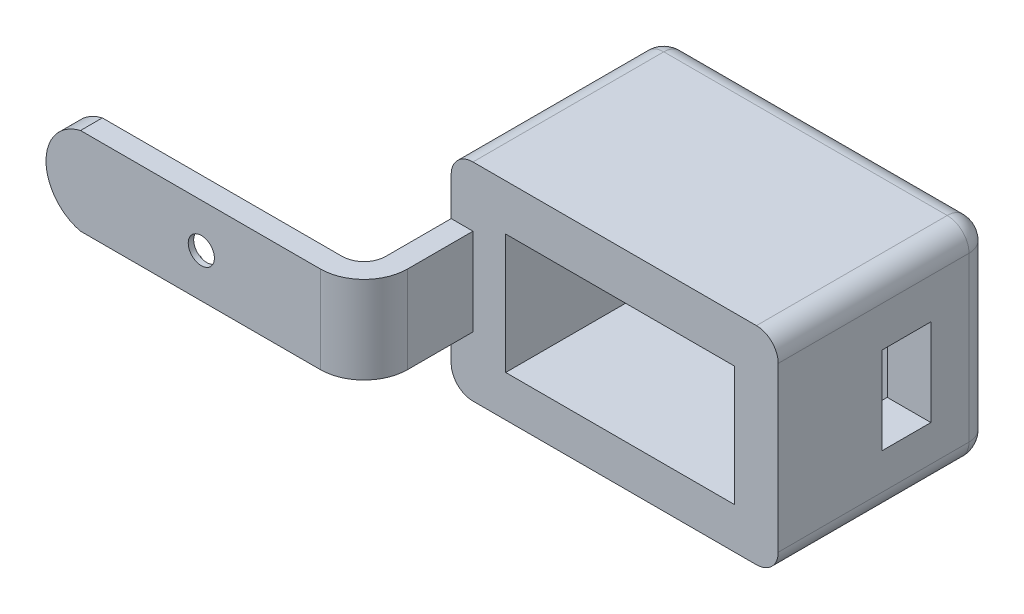
from build123d import *

# Parameters (mm, degrees)
BOSS_EXTRUDE1_DEPTH  = 4
CUT_EXTRUDE1_DEPTH   = 3
SKETCH5_W            = 51
SKETCH5_H            = 16
BOSS_EXTRUDE2_DEPTH  = 4
BOSS_EXTRUDE15_DEPTH = 31
SKETCH20_R           = 2.4
CUT_EXTRUDE26_DEPTH  = 1
FILLET8_R            = 4
FILLET12_R           = 8
CUT_EXTRUDE_8_DEPTH  = 29
SKETCH_8_W           = 9
SKETCH_8_H           = 16
CUT_EXTRUDE_10_DEPTH = 8
SKETCH_10_W          = 60
SKETCH_10_H          = 38
EXTRUDE_2_DEPTH      = 8
FILLET_3_R           = 4
FILLET_4_R           = 4
FILLET_5_R           = 4
FILLET_6_R           = 4


with BuildPart() as part:
    # Sketch2 → Boss-Extrude1 (new body)
    with BuildSketch(Plane.XY):
        with BuildLine():
            Line((23.733047461, 11.63962887), (23.733047461, -4.36037113))
            Line((23.733047461, -4.36037113), (-24.266952539, -4.36037113))
            ThreePointArc((-24.266952539, -4.36037113), (-30.597931628, 3.63962887), (-24.266952539, 11.63962887))
            Line((-24.266952539, 11.63962887), (23.733047461, 11.63962887))
        make_face()
    extrude(amount=BOSS_EXTRUDE1_DEPTH)

    # Sketch1 → Cut-Extrude1 (cut)
    with BuildSketch(Plane.XY):
        with BuildLine():
            Line((-6.25004119, 8.63962887), (-20.04279291, 6.23962887))
            ThreePointArc((-20.04279291, 6.23962887), (-22.105421524, 3.63962887), (-20.04279291, 1.03962887))
            Line((-20.04279291, 1.03962887), (-6.25004119, -1.36037113))
            ThreePointArc((-6.25004119, -1.36037113), (-2.105421524, -2.86037113), (2.039198142, -1.36037113))
            Line((2.039198142, -1.36037113), (15.831949862, 1.03962887))
            ThreePointArc((15.831949862, 1.03962887), (17.894578476, 3.63962887), (15.831949862, 6.23962887))
            Line((15.831949862, 6.23962887), (2.039198142, 8.63962887))
            ThreePointArc((2.039198142, 8.63962887), (-2.105421524, 10.13962887), (-6.25004119, 8.63962887))
        make_face()
    extrude(amount=CUT_EXTRUDE1_DEPTH, mode=Mode.SUBTRACT)

    # Sketch5 → Boss-Extrude2 (add)
    with BuildSketch(Plane(origin=(23.733047461, 0, 0), x_dir=(0, 0, -1), z_dir=(1, 0, 0))):
        with Locations((21.5, 3.63962887)):
            Rectangle(SKETCH5_W, SKETCH5_H)
    extrude(amount=BOSS_EXTRUDE2_DEPTH)

    # Sketch6 → Boss-Extrude15 (add)
    with BuildSketch(Plane(origin=(0, 0, -47), x_dir=(-1, 0, 0), z_dir=(0, 0, -1))):
        Polygon((-30.946192459, -15.36037113), (-83.733047461, -15.36037113), (-83.733047461, 22.63962887), (-23.733047461, 22.63962887), (-23.733047461, -15.36037113), align=None)
    extrude(amount=-BOSS_EXTRUDE15_DEPTH)

    # Sketch20 → Cut-Extrude26 (cut)
    with BuildSketch(Plane(origin=(0, 0, 3), x_dir=(-1, 0, 0), z_dir=(0, 0, -1))):
        with Locations((2.105421524, 3.63962887)):
            Circle(SKETCH20_R)
    extrude(amount=-CUT_EXTRUDE26_DEPTH, mode=Mode.SUBTRACT)

    # Fillet8
    fillet8_edges = [part.edges().sort_by_distance(p)[0] for p in [
        (23.733047461, 3.63962887, 0),
    ]]
    fillet(fillet8_edges, radius=FILLET8_R)

    # Fillet12
    fillet12_edges = [part.edges().sort_by_distance(p)[0] for p in [
        (27.733047461, 3.63962887, 4),
    ]]
    fillet(fillet12_edges, radius=FILLET12_R)

    # 草圖5 → 除料-伸長8 (cut)
    with BuildSketch(Plane.XY.offset(-16)):
        Polygon((75.733047461, -7.806095257), (75.733047461, 14.193904743), (33.733047461, 14.193904743), (33.733047461, 3.193904743), (33.733047461, -7.806095257), align=None)
    extrude(amount=-CUT_EXTRUDE_8_DEPTH, mode=Mode.SUBTRACT)

    # 草圖8 → 除料-伸長10 (cut)
    with BuildSketch(Plane(origin=(83.733047461, 0, 0), x_dir=(0, 0, -1), z_dir=(1, 0, 0))):
        with Locations((39.5, 3.238584995)):
            Rectangle(SKETCH_8_W, SKETCH_8_H)
    extrude(amount=-CUT_EXTRUDE_10_DEPTH, mode=Mode.SUBTRACT)

    # 草圖10 → 填料-伸長2 (add)
    with BuildSketch(Plane(origin=(0, 0, -47), x_dir=(-1, 0, 0), z_dir=(0, 0, -1))):
        with Locations((-53.733047461, 3.63962887)):
            Rectangle(SKETCH_10_W, SKETCH_10_H)
    extrude(amount=EXTRUDE_2_DEPTH)

    # 圓角3
    fillet_3_edges = [part.edges().sort_by_distance(p)[0] for p in [
        (53.733047461, 22.63962887, -55),
    ]]
    fillet(fillet_3_edges, radius=FILLET_3_R)

    # 圓角4
    fillet_4_edges = [part.edges().sort_by_distance(p)[0] for p in [
        (53.733047461, -15.36037113, -55),
    ]]
    fillet(fillet_4_edges, radius=FILLET_4_R)

    # 圓角5
    fillet_5_edges = [part.edges().sort_by_distance(p)[0] for p in [
        (83.733047461, 22.63962887, -33.5),
    ]]
    fillet(fillet_5_edges, radius=FILLET_5_R)

    # 圓角6
    fillet_6_edges = [part.edges().sort_by_distance(p)[0] for p in [
        (23.733047461, -15.36037113, -33.5),
    ]]
    fillet(fillet_6_edges, radius=FILLET_6_R)


solid = part.part
